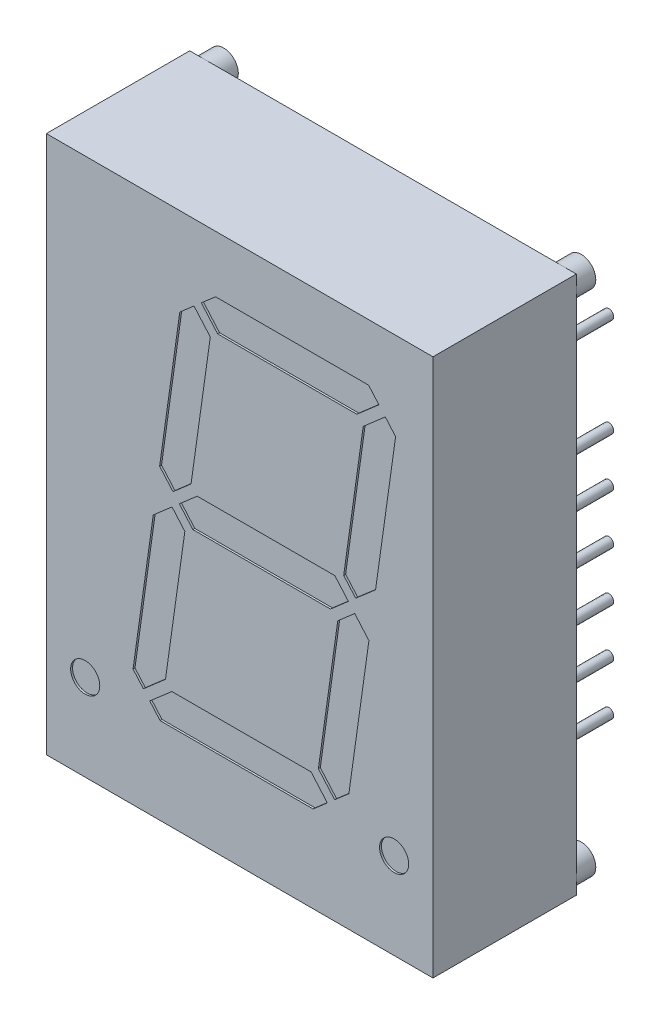
from build123d import *

# Parameters (mm, degrees)
EXTRUDE_START       = 1
SKETCH_1_W          = 19.9
SKETCH_1_H          = 27.69
EXTRUDE_1_DEPTH     = 7.38
SKETCH_3_R          = 0.75
EXTRUDE_3_DEPTH     = 1
SKETCH_2_R          = 0.25
EXTRUDE_2_DEPTH     = 4
SKETCH_4_R          = 0.75
CUT_EXTRUDE_1_DEPTH = 0.1


with BuildPart() as part:
    # Эскиз1 → Бобышка-Вытянуть1 (new body)
    with BuildSketch(Plane.XY.offset(EXTRUDE_START)):
        Rectangle(SKETCH_1_W, SKETCH_1_H)
    extrude(amount=EXTRUDE_1_DEPTH)

    # Эскиз3 → Бобышка-Вытянуть3 (add)
    with BuildSketch(Plane(origin=(0, 0, 1), x_dir=(-1, 0, 0), z_dir=(0, 0, -1))):
        with Locations((-9.2, 13.095)):
            Circle(SKETCH_3_R)
        with Locations((9.2, 13.095)):
            Circle(SKETCH_3_R)
        with Locations((9.2, -13.095)):
            Circle(SKETCH_3_R)
        with Locations((-9.2, -13.095)):
            Circle(SKETCH_3_R)
    extrude(amount=EXTRUDE_3_DEPTH)

    # Эскиз2 → Бобышка-Вытянуть2 (add)
    with BuildSketch(Plane(origin=(0, 0, 1), x_dir=(-1, 0, 0), z_dir=(0, 0, -1))):
        with Locations((-7.62, -8.89)):
            Circle(SKETCH_2_R)
        with Locations((7.62, -3.81)):
            Circle(SKETCH_2_R)
        with Locations((7.62, -1.27)):
            Circle(SKETCH_2_R)
        with Locations((7.62, 1.27)):
            Circle(SKETCH_2_R)
        with Locations((7.62, 3.81)):
            Circle(SKETCH_2_R)
        with Locations((7.62, 6.35)):
            Circle(SKETCH_2_R)
        with Locations((7.62, 8.89)):
            Circle(SKETCH_2_R)
        with Locations((-7.62, -6.35)):
            Circle(SKETCH_2_R)
        with Locations((-7.62, -3.81)):
            Circle(SKETCH_2_R)
        with Locations((-7.62, -1.27)):
            Circle(SKETCH_2_R)
        with Locations((-7.62, 1.27)):
            Circle(SKETCH_2_R)
        with Locations((-7.62, 3.81)):
            Circle(SKETCH_2_R)
        with Locations((-7.62, 8.89)):
            Circle(SKETCH_2_R)
    extrude(amount=EXTRUDE_2_DEPTH)

    # Эскиз4 → Вырез-Вытянуть1 (cut)
    with BuildSketch(Plane.XY.offset(8.38)):
        with Locations((-7.95, -9.395)):
            Circle(SKETCH_4_R)
        with Locations((7.95, -9.395)):
            Circle(SKETCH_4_R)
        Polygon((-3.10454324, 0.765), (-2.184248514, 1.565), (4.899303826, 1.565), (5.594733216, 0.765), (4.67443849, -0.035), (-2.409113849, -0.035), align=None)
        Polygon((-4.096222413, -9.395), (3.780432652, -9.395), (4.512049983, -8.759014757), (3.674044739, -7.795), (-3.490293806, -7.795), (-4.627637046, -8.783677395), align=None)
        Polygon((5.048482741, -0.37235479), (4.05139953, -7.466970486), (4.889404773, -8.430985243), (5.621022104, -7.795), (6.652963591, -0.45235479), (5.922762731, 0.38764521), align=None)
        Polygon((-4.119895806, 1.933029514), (-3.432572754, 1.14235479), (-2.501550526, 1.951680066), (-1.51139953, 8.996970486), (-2.349404773, 9.960985243), (-3.081022104, 9.325), align=None)
        Polygon((-4.448207492, -0.403029514), (-3.48189803, 0.436970486), (-2.821240109, -0.323029514), (-3.818323321, -7.41764521), (-4.955666561, -8.406322605), (-5.487081194, -7.795), align=None)
        Polygon((-1.240432652, 10.925), (-1.972049983, 10.289014757), (-1.134044739, 9.325), (6.030293806, 9.325), (7.167637046, 10.313677395), (6.636222413, 10.925), align=None)
        Polygon((6.358323321, 8.94764521), (7.495666561, 9.936322605), (8.027081194, 9.325), (6.995139707, 1.98235479), (5.972088006, 1.093029514), (5.354307894, 1.803704239), align=None)
    extrude(amount=-CUT_EXTRUDE_1_DEPTH, mode=Mode.SUBTRACT)


solid = part.part
